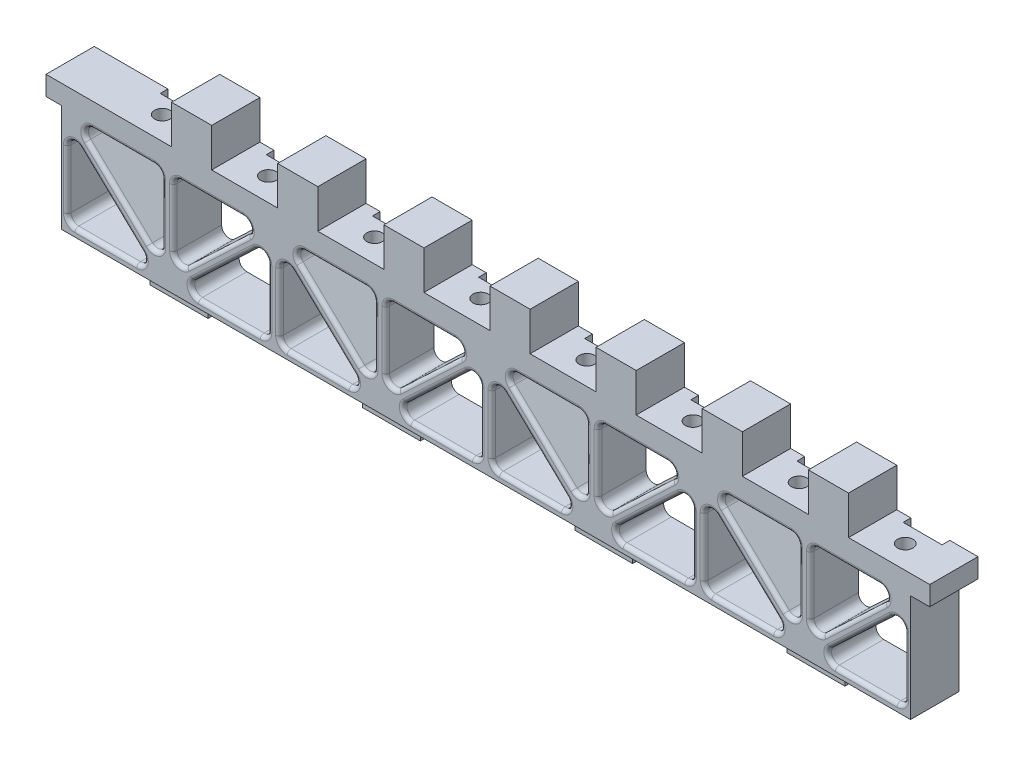
from build123d import *

# Parameters (mm, degrees)
SKETCH1_W              = 228.98
SKETCH1_H              = 12.5
BOSS_EXTRUDE1_DEPTH    = 5
SKETCH2_W              = 10.1
SKETCH2_H              = 2
CUT_EXTRUDE1_DEPTH     = 3.05
SKETCH3_R              = 2
CUT_EXTRUDE2_DEPTH     = 4
LPATTERN1_COUNT        = 8
LPATTERN1_PITCH        = 27.5
BOSS_EXTRUDE2_DEPTH    = 12.5
FILLET1_R              = 2
FILLET2_R              = 1
SKETCH5_W              = 15
SKETCH5_H              = 6.4
BOSS_EXTRUDE3_DEPTH    = 4
LPATTERN2_COUNT        = 4
LPATTERN2_PITCH        = 55
FILLET1_OF_LPATTERN2_R = 2
FILLET2_OF_LPATTERN2_R = 1
SKETCH6_W              = 10.4
SKETCH6_H              = 12.5
BOSS_EXTRUDE4_DEPTH    = 10
LPATTERN3_COUNT        = 7
LPATTERN3_PITCH        = 27.5


with BuildPart() as part:
    # Sketch1 → Boss-Extrude1 (new body)
    with BuildSketch(Plane(origin=(0, 0, 0), x_dir=(1, 0, 0), z_dir=(0, 1, 0))):
        with Locations((114.49, 6.25)):
            Rectangle(SKETCH1_W, SKETCH1_H)
    extrude(amount=BOSS_EXTRUDE1_DEPTH)

    # Sketch2 → Cut-Extrude1 (cut)
    with BuildSketch(Plane(origin=(0, 5, 0), x_dir=(1, 0, 0), z_dir=(0, 1, 0))):
        with Locations((24.13, 11.5)):
            Rectangle(SKETCH2_W, SKETCH2_H)
    cut_extrude1 = extrude(amount=-CUT_EXTRUDE1_DEPTH, mode=Mode.SUBTRACT)

    # Sketch3 → Cut-Extrude2 (cut)
    with BuildSketch(Plane(origin=(0, 5, 0), x_dir=(1, 0, 0), z_dir=(0, 1, 0))):
        with Locations((24.13, 6)):
            Circle(SKETCH3_R)
    cut_extrude2 = extrude(amount=-CUT_EXTRUDE2_DEPTH, mode=Mode.SUBTRACT)

    # LPattern1: Cut-Extrude1, Cut-Extrude2 ×8
    with Locations(*[(i * LPATTERN1_PITCH, 0, 0) for i in range(1, LPATTERN1_COUNT)]):
        add(cut_extrude1, mode=Mode.SUBTRACT)
        add(cut_extrude2, mode=Mode.SUBTRACT)

    # Sketch4 → Boss-Extrude2 (add)
    with BuildSketch(Plane.XY):
        Polygon((4, 0.20458934), (31.5, 0.20458934), (31.5, 0), (59, 0), (59, -27.79541066), (31.5, -27.79541066), (4, -27.79541066), align=None)
        Polygon((30, -1.29541066), (7, -1.29541066), (30, -23.197334449), align=None, mode=Mode.SUBTRACT)
        Polygon((5.5, -3.893486871), (5.5, -25.79541066), (28.5, -25.79541066), align=None, mode=Mode.SUBTRACT)
        Polygon((33, -1.5), (33, -23.197334449), (56, -1.5), align=None, mode=Mode.SUBTRACT)
        Polygon((34.5, -25.79541066), (57.5, -25.79541066), (57.5, -4.098076211), align=None, mode=Mode.SUBTRACT)
    boss_extrude2 = extrude(amount=-BOSS_EXTRUDE2_DEPTH)

    # Fillet1
    fillet1_edges = [part.edges().sort_by_distance(p)[0] for p in [
        (28.5, -25.79541066, -6.25),
        (5.5, -25.79541066, -6.25),
        (5.5, -3.893486871, -6.25),
        (30, -23.197334449, -6.25),
        (7, -1.29541066, -6.25),
        (30, -1.29541066, -6.25),
        (56, -1.5, -6.25),
        (33, -23.197334449, -6.25),
        (33, -1.5, -6.25),
        (57.5, -4.098076211, -6.25),
        (57.5, -25.79541066, -6.25),
        (34.5, -25.79541066, -6.25),
    ]]
    fillet(fillet1_edges, radius=FILLET1_R)

    # Fillet2
    fillet2_edges = [part.edges().sort_by_distance(p)[0] for p in [
        (57.5, -16.264853982, 0),
        (47.517323418, -25.79541066, 0),
        (46.144908627, -14.81004209, 0),
        (20.000234593, -1.29541066, 0),
        (30, -10.913247715, 0),
        (33, -11.030556678, 0),
        (42.982676582, -1.5, 0),
        (44.355091373, -12.48536857, 0),
        (15.499765407, -25.79541066, 0),
        (5.5, -16.177573605, 0),
        (16.878982031, -14.72920849, 0),
        (18.621017969, -12.36161283, 0),
        (56.914213562, -25.209624222, 0),
        (56.292202758, -6.897883737, 0),
        (29.414213562, -1.881197098, 0),
        (33.585786438, -2.085786438, 0),
        (52.824065592, -2.761631455, 0),
        (6.085786438, -25.209624222, 0),
        (6.712101925, -6.721471981, 0),
        (10.143491772, -2.55268939, 0),
        (37.675934408, -24.533779205, 0),
        (25.356508228, -24.538131931, 0),
        (28.787898075, -20.369349339, 0),
        (34.207797242, -20.397526923, 0),
    ]]
    fillet(fillet2_edges, radius=FILLET2_R)

    # Sketch5 → Boss-Extrude3 (add)
    with BuildSketch(Plane.XZ.offset(27.79541066)):
        with Locations((31.5, -6.2)):
            Rectangle(SKETCH5_W, SKETCH5_H)
    boss_extrude3 = extrude(amount=BOSS_EXTRUDE3_DEPTH)

    # LPattern2: Boss-Extrude2, Boss-Extrude3 ×4
    with Locations(*[(i * LPATTERN2_PITCH, 0, 0) for i in range(1, LPATTERN2_COUNT)]):
        add(boss_extrude2)
        add(boss_extrude3)

    # Fillet1 of LPattern2
    fillet1_of_lpattern2_edges = [part.edges().sort_by_distance(p)[0] for p in [
        (83.5, -25.79541066, -6.25),
        (60.5, -25.79541066, -6.25),
        (60.5, -3.893486871, -6.25),
        (85, -23.197334449, -6.25),
        (62, -1.29541066, -6.25),
        (85, -1.29541066, -6.25),
        (111, -1.5, -6.25),
        (88, -23.197334449, -6.25),
        (88, -1.5, -6.25),
        (112.5, -4.098076211, -6.25),
        (112.5, -25.79541066, -6.25),
        (89.5, -25.79541066, -6.25),
        (138.5, -25.79541066, -6.25),
        (115.5, -25.79541066, -6.25),
        (115.5, -3.893486871, -6.25),
        (140, -23.197334449, -6.25),
        (117, -1.29541066, -6.25),
        (140, -1.29541066, -6.25),
        (166, -1.5, -6.25),
        (143, -23.197334449, -6.25),
        (143, -1.5, -6.25),
        (167.5, -4.098076211, -6.25),
        (167.5, -25.79541066, -6.25),
        (144.5, -25.79541066, -6.25),
        (193.5, -25.79541066, -6.25),
        (170.5, -25.79541066, -6.25),
        (170.5, -3.893486871, -6.25),
        (195, -23.197334449, -6.25),
        (172, -1.29541066, -6.25),
        (195, -1.29541066, -6.25),
        (221, -1.5, -6.25),
        (198, -23.197334449, -6.25),
        (198, -1.5, -6.25),
        (222.5, -4.098076211, -6.25),
        (222.5, -25.79541066, -6.25),
        (199.5, -25.79541066, -6.25),
    ]]
    fillet(fillet1_of_lpattern2_edges, radius=FILLET1_OF_LPATTERN2_R)

    # Fillet2 of LPattern2
    fillet2_of_lpattern2_edges = [part.edges().sort_by_distance(p)[0] for p in [
        (112.5, -16.264853982, 0),
        (102.517323418, -25.79541066, 0),
        (101.144908627, -14.81004209, 0),
        (75.000234593, -1.29541066, 0),
        (85, -10.913247715, 0),
        (88, -11.030556678, 0),
        (97.982676582, -1.5, 0),
        (99.355091373, -12.48536857, 0),
        (70.499765407, -25.79541066, 0),
        (60.5, -16.177573605, 0),
        (71.878982031, -14.72920849, 0),
        (73.621017969, -12.36161283, 0),
        (111.914213562, -25.209624222, 0),
        (111.292202758, -6.897883737, 0),
        (84.414213562, -1.881197098, 0),
        (88.585786438, -2.085786438, 0),
        (107.824065592, -2.761631455, 0),
        (61.085786438, -25.209624222, 0),
        (61.712101925, -6.721471981, 0),
        (65.143491772, -2.55268939, 0),
        (92.675934408, -24.533779205, 0),
        (80.356508228, -24.538131931, 0),
        (83.787898075, -20.369349339, 0),
        (89.207797242, -20.397526923, 0),
        (167.5, -16.264853982, 0),
        (157.517323418, -25.79541066, 0),
        (156.144908627, -14.81004209, 0),
        (130.000234593, -1.29541066, 0),
        (140, -10.913247715, 0),
        (143, -11.030556678, 0),
        (152.982676582, -1.5, 0),
        (154.355091373, -12.48536857, 0),
        (125.499765407, -25.79541066, 0),
        (115.5, -16.177573605, 0),
        (126.878982031, -14.72920849, 0),
        (128.621017969, -12.36161283, 0),
        (166.914213562, -25.209624222, 0),
        (166.292202758, -6.897883737, 0),
        (139.414213562, -1.881197098, 0),
        (143.585786438, -2.085786438, 0),
        (162.824065592, -2.761631455, 0),
        (116.085786438, -25.209624222, 0),
        (116.712101925, -6.721471981, 0),
        (120.143491772, -2.55268939, 0),
        (147.675934408, -24.533779205, 0),
        (135.356508228, -24.538131931, 0),
        (138.787898075, -20.369349339, 0),
        (144.207797242, -20.397526923, 0),
        (222.5, -16.264853982, 0),
        (212.517323418, -25.79541066, 0),
        (211.144908627, -14.81004209, 0),
        (185.000234593, -1.29541066, 0),
        (195, -10.913247715, 0),
        (198, -11.030556678, 0),
        (207.982676582, -1.5, 0),
        (209.355091373, -12.48536857, 0),
        (180.499765407, -25.79541066, 0),
        (170.5, -16.177573605, 0),
        (181.878982031, -14.72920849, 0),
        (183.621017969, -12.36161283, 0),
        (221.914213562, -25.209624222, 0),
        (221.292202758, -6.897883737, 0),
        (194.414213562, -1.881197098, 0),
        (198.585786438, -2.085786438, 0),
        (217.824065592, -2.761631455, 0),
        (171.085786438, -25.209624222, 0),
        (171.712101925, -6.721471981, 0),
        (175.143491772, -2.55268939, 0),
        (202.675934408, -24.533779205, 0),
        (190.356508228, -24.538131931, 0),
        (193.787898075, -20.369349339, 0),
        (199.207797242, -20.397526923, 0),
    ]]
    fillet(fillet2_of_lpattern2_edges, radius=FILLET2_OF_LPATTERN2_R)

    # Sketch6 → Boss-Extrude4 (add)
    with BuildSketch(Plane(origin=(0, 5, 0), x_dir=(1, 0, 0), z_dir=(0, 1, 0))):
        with Locations((37.73, 6.25)):
            Rectangle(SKETCH6_W, SKETCH6_H)
    boss_extrude4 = extrude(amount=BOSS_EXTRUDE4_DEPTH)

    # LPattern3: Boss-Extrude4 ×7
    with Locations(*[(i * LPATTERN3_PITCH, 0, 0) for i in range(1, LPATTERN3_COUNT)]):
        add(boss_extrude4)


solid = part.part
